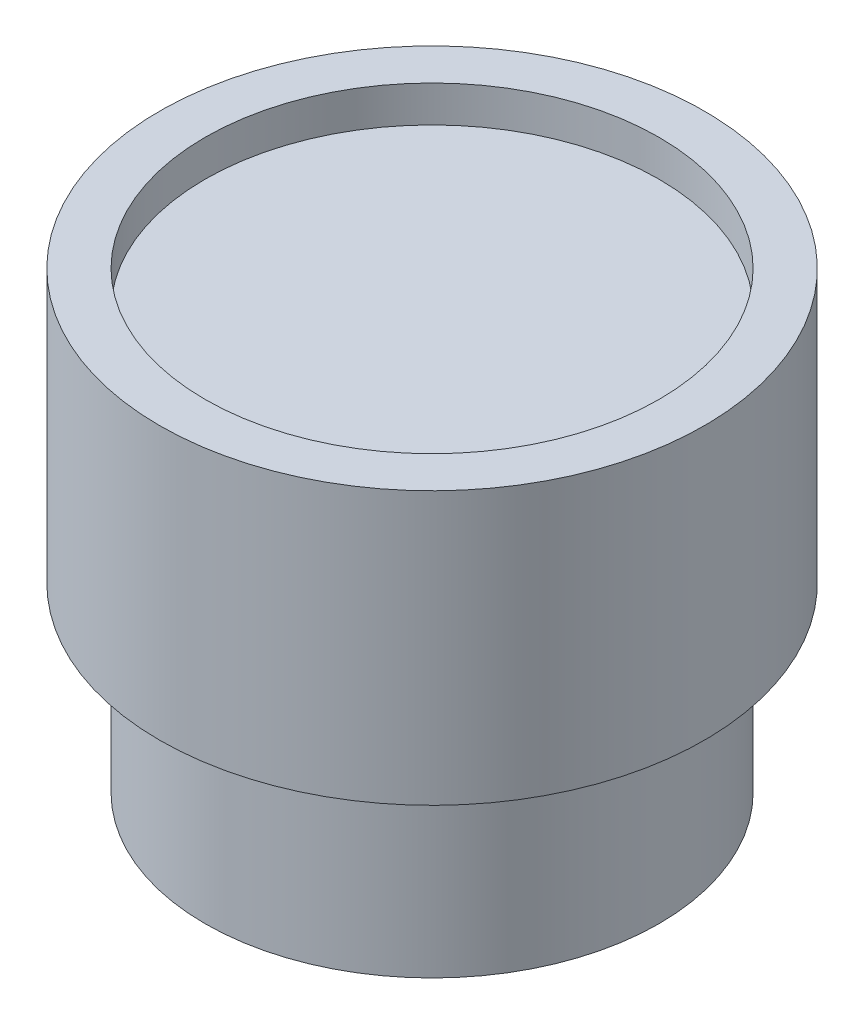
from build123d import *

# Parameters (mm, degrees)
SKETCH1_R           = 12.5
BOSS_EXTRUDE1_DEPTH = 10
SKETCH2_R           = 15
BOSS_EXTRUDE2_DEPTH = 15
SKETCH3_R           = 12.5
CUT_EXTRUDE1_DEPTH  = 2


with BuildPart() as part:
    # Sketch1 → Boss-Extrude1 (new body)
    with BuildSketch(Plane(origin=(0, 0, 0), x_dir=(1, 0, 0), z_dir=(0, 1, 0))):
        Circle(SKETCH1_R)
    extrude(amount=BOSS_EXTRUDE1_DEPTH)

    # Sketch2 → Boss-Extrude2 (add)
    with BuildSketch(Plane(origin=(0, 10, 0), x_dir=(1, 0, 0), z_dir=(0, 1, 0))):
        Circle(SKETCH2_R)
    extrude(amount=BOSS_EXTRUDE2_DEPTH)

    # Sketch3 → Cut-Extrude1 (cut)
    with BuildSketch(Plane(origin=(0, 25, 0), x_dir=(1, 0, 0), z_dir=(0, 1, 0))):
        Circle(SKETCH3_R)
    extrude(amount=-CUT_EXTRUDE1_DEPTH, mode=Mode.SUBTRACT)


solid = part.part
